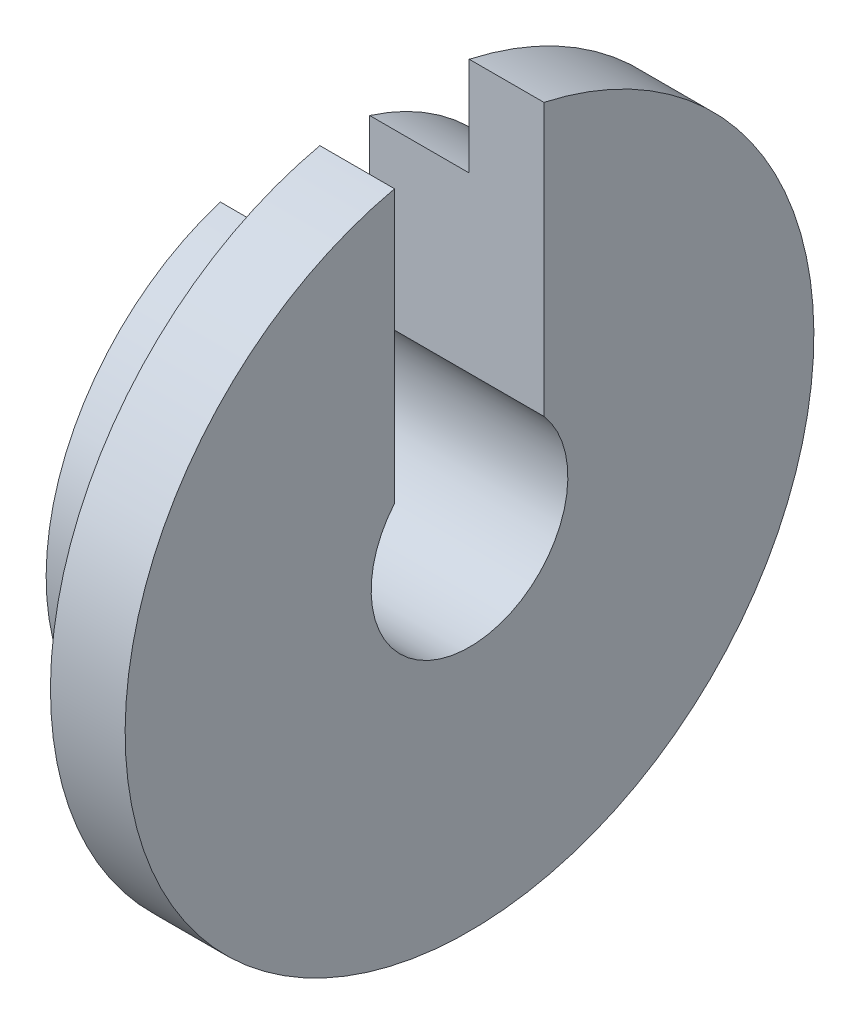
from build123d import *
from build123d.topology import SkipClean

# Parameters (mm, degrees)
BOSS_EXTRUDE1_DEPTH = 0.762
BOSS_EXTRUDE2_DEPTH = 1.778


with BuildPart() as part:
    # Sketch1 → Boss-Extrude1 (new body)
    with BuildSketch(Plane(origin=(0, 0, 0), x_dir=(0, 0, -1), z_dir=(1, 0, 0))):
        with BuildLine():
            Line((0.759321469, 3.430139815), (0.759321469, 0.655775721))
            ThreePointArc((0.759321469, 0.655775721), (0.004117603, -1.003291551), (-0.764678531, 0.649521081))
            Line((-0.764678531, 0.649521081), (-0.764678531, 3.428949546))
            ThreePointArc((-0.764678531, 3.428949546), (0.00274385, -3.51317815), (0.759321469, 3.430139815))
        make_face()
    extrude(amount=BOSS_EXTRUDE1_DEPTH)

    # Sketch3 → Boss-Extrude2 (add)
    with SkipClean():  # the faces are left unmerged after this step: merging them gives an invalid solid
        with BuildSketch(Plane(origin=(0.762, 0, 0), x_dir=(0, 0, -1), z_dir=(1, 0, 0))):
            with BuildLine():
                Line((-0.764678531, 2.423347628), (-0.764678531, 0.649521081))
                ThreePointArc((-0.764678531, 0.649521081), (0.004117603, -1.003291551), (0.759321469, 0.655775721))
                Line((0.759321469, 0.655775721), (0.759321469, 2.425031523))
                ThreePointArc((0.759321469, 2.425031523), (0.00280774, -2.541129493), (-0.764678531, 2.423347628))
            make_face()
        extrude(amount=-BOSS_EXTRUDE2_DEPTH)


solid = part.part
